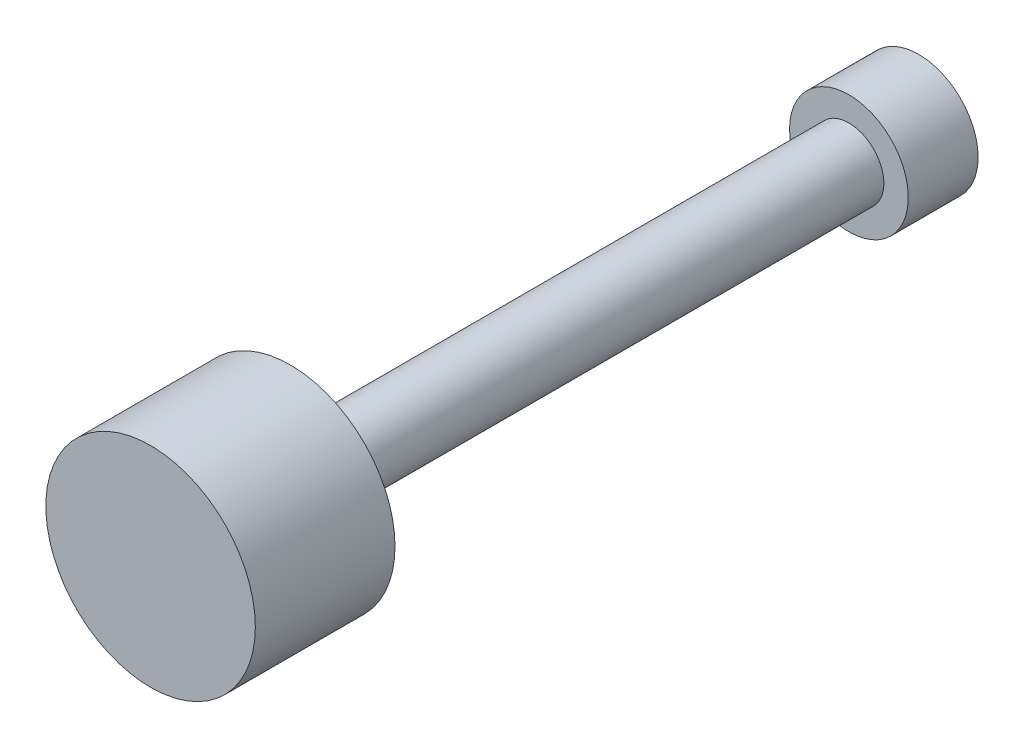
from build123d import *

# Parameters (mm, degrees)
SKETCH2_R           = 50
BOSS_EXTRUDE1_DEPTH = 1000
SKETCH3_R           = 150
BOSS_EXTRUDE2_DEPTH = 200
SKETCH4_R           = 85
BOSS_EXTRUDE3_DEPTH = 100


with BuildPart() as part:
    # Sketch2 → Boss-Extrude1 (new body)
    with BuildSketch(Plane.XY):
        Circle(SKETCH2_R)
    extrude(amount=BOSS_EXTRUDE1_DEPTH)

    # Sketch3 → Boss-Extrude2 (add)
    with BuildSketch(Plane.XY.offset(1000)):
        Circle(SKETCH3_R)
    extrude(amount=-BOSS_EXTRUDE2_DEPTH)

    # Sketch4 → Boss-Extrude3 (add)
    with BuildSketch(Plane(origin=(0, 0, 0), x_dir=(-1, 0, 0), z_dir=(0, 0, -1))):
        Circle(SKETCH4_R)
    extrude(amount=BOSS_EXTRUDE3_DEPTH)


solid = part.part
